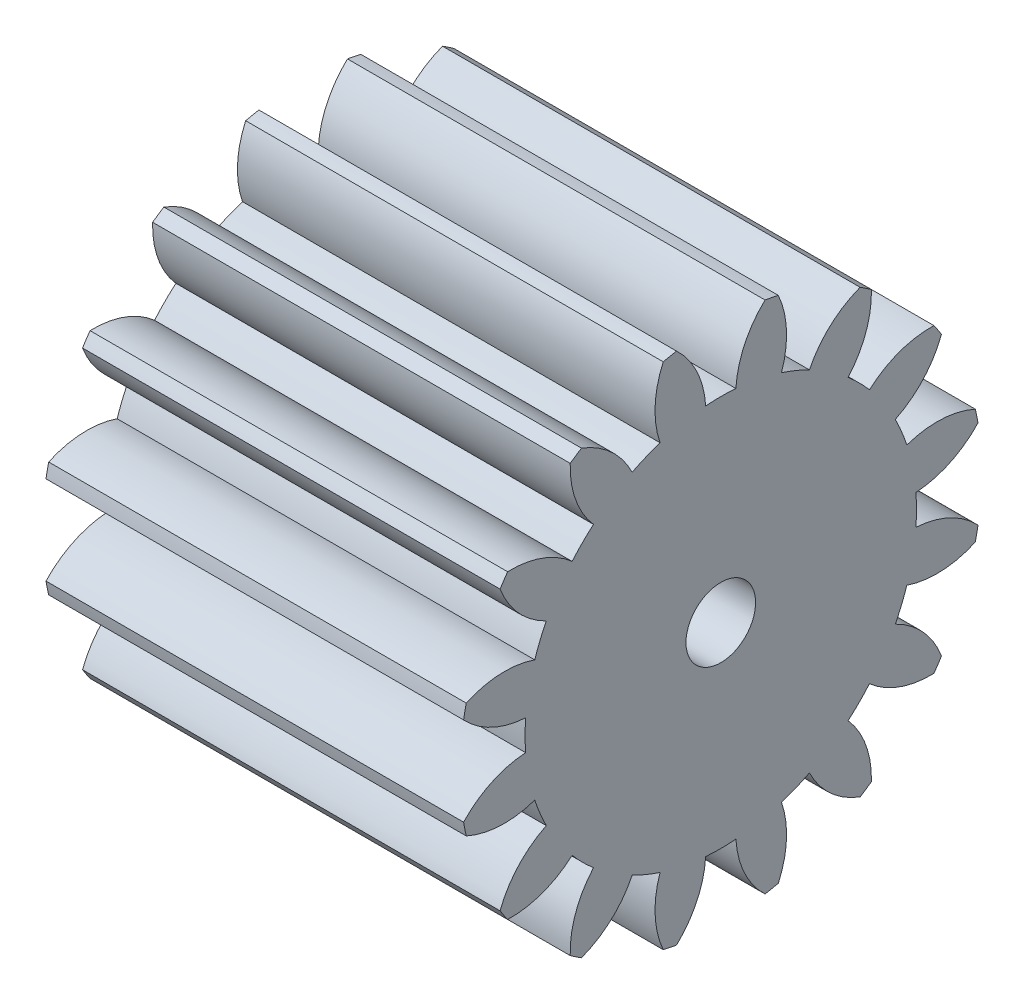
from build123d import *

# Parameters (mm, degrees)
BASPROSKE_W     = 18
BASPROSKE_H     = 11.25
TOOTHCUT_DEPTH  = 25.023426067
TEETHCUTS_COUNT = 16
TEETHCUTS_ANGLE = 337.5
BORSKE_R        = 1.5
BORE_DEPTH      = 50.0000508


with BuildPart() as part:
    # BasProSke → Base-Revolve (revolve)
    with BuildSketch(Plane(origin=(0, 0, 0), x_dir=(1, 0, 0), z_dir=(0, 1, 0)), mode=Mode.PRIVATE) as base_revolve_sk:
        with Locations((9, 5.625)):
            Rectangle(BASPROSKE_W, BASPROSKE_H)
    revolve(base_revolve_sk.sketch.rotate(Axis((-10, 0, 0), (1, 0, 0)), 180), axis=Axis((-10, 0, 0), (1, 0, 0)))

    # TooCutSke → ToothCut (cut, through all)
    with BuildSketch(Plane(origin=(0, 0, 0), x_dir=(0, 0, -1), z_dir=(1, 0, 0))):
        with BuildLine():
            ThreePointArc((0.651061533, 8.411340626), (0, 8.4365), (-0.651061533, 8.411340626))
            ThreePointArc((-0.651061533, 8.411340626), (-1.029874156, 9.883978829), (-1.930926138, 11.108832945))
            ThreePointArc((-1.930926138, 11.108832945), (0, 11.2754), (1.930926138, 11.108832945))
            ThreePointArc((1.930926138, 11.108832945), (1.029874156, 9.883978829), (0.651061533, 8.411340626))
        make_face()
    toothcut = extrude(amount=TOOTHCUT_DEPTH, mode=Mode.SUBTRACT)

    # TeethCuts: ToothCut ×16 about axis
    teethcuts_axis = Axis((-10, 0, 0), (1, 0, 0))
    for i in range(1, TEETHCUTS_COUNT):
        add(toothcut.rotate(teethcuts_axis, i * TEETHCUTS_ANGLE / (TEETHCUTS_COUNT - 1)), mode=Mode.SUBTRACT)

    # BorSke → Bore (cut, symmetric)
    with BuildSketch(Plane(origin=(0, 0, 0), x_dir=(0, 0, -1), z_dir=(1, 0, 0))):
        with Locations(Location((0, 0, 0), (0, 0, 180))):
            Circle(BORSKE_R)
    extrude(amount=BORE_DEPTH, both=True, mode=Mode.SUBTRACT)


solid = part.part
